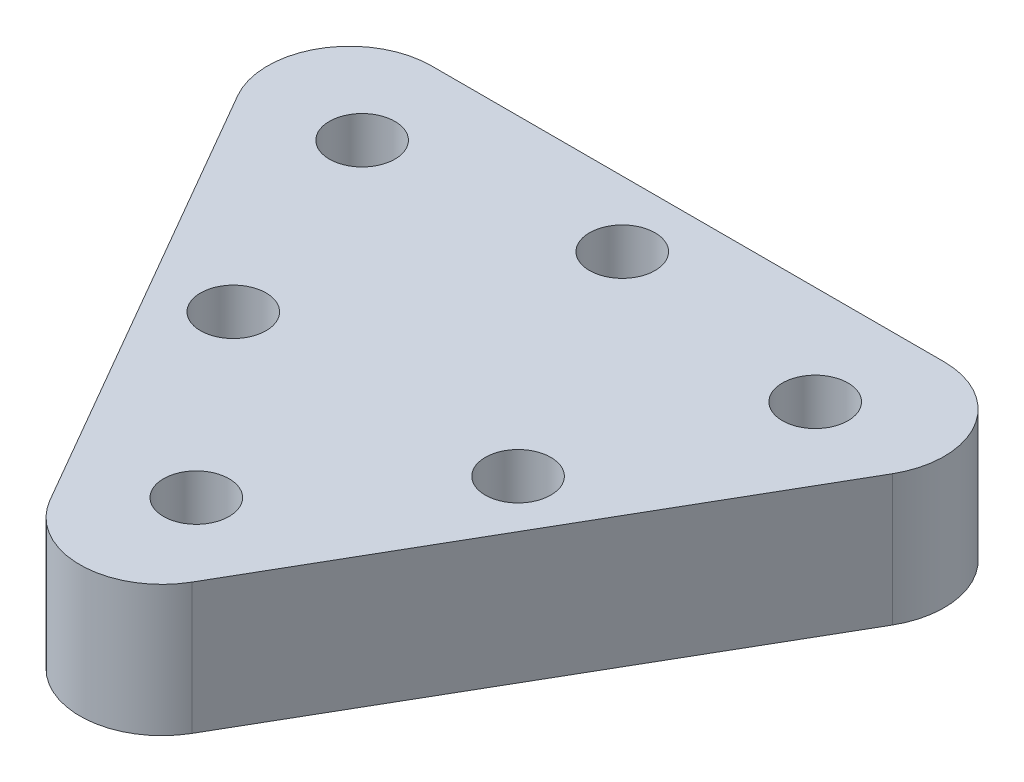
from build123d import *

# Parameters (mm, degrees)
SKETCH1_R                    = 1
EXTRUDE1_DEPTH               = 4
SKETCH1_3_R                  = 2.38125
SKETCH1_3_R_2                = 1
EXTRUDE4_DEPTH               = 2
M2X0_4_TAPPED_HOLE1_D        = 1.6
M2X0_4_TAPPED_HOLE1_DEPTH    = 3
M2X0_4_TAPPED_HOLE1_TIP      = 0.480688495
F_2_0_2_DIAMETER_HOLE1_D     = 2
F_2_0_2_DIAMETER_HOLE1_DEPTH = 10
F_2_0_2_DIAMETER_HOLE1_TIP   = 0.600860619


with BuildPart() as part:
    # Sketch1 → Extrude1 (new body)
    with BuildSketch(Plane(origin=(0, 0, 0), x_dir=(1, 0, 0), z_dir=(0, 1, 0))):
        with BuildLine():
            ThreePointArc((-3.020977638, 7.066192399), (-5.186041147, 5.816192399), (-5.186041147, 3.316192399))
            Line((-5.186041147, 3.316192399), (2.637731834, -10.234979911))
            ThreePointArc((2.637731834, -10.234979911), (4.802795343, -11.484979911), (6.967858853, -10.234979911))
            Line((6.967858853, -10.234979911), (14.791631834, 3.316192399))
            ThreePointArc((14.791631834, 3.316192399), (14.791631834, 5.816192399), (12.626568324, 7.066192399))
            Line((12.626568324, 7.066192399), (-3.020977638, 7.066192399))
        make_face()
        with Locations((4.802795343, -7.933807601)):
            Circle(SKETCH1_R, mode=Mode.SUBTRACT)
        with Locations((-2.110635714, 4.040606244)):
            Circle(SKETCH1_R, mode=Mode.SUBTRACT)
        with Locations((11.7162264, 4.040606244)):
            Circle(SKETCH1_R, mode=Mode.SUBTRACT)
    extrude(amount=EXTRUDE1_DEPTH)

    # Sketch1_3 → Extrude4 (cut)
    # profile 1 of 3: a face of its own
    with BuildSketch(Plane(origin=(0, 0, 0), x_dir=(1, 0, 0), z_dir=(0, 1, 0))):
        with Locations((-2.110635714, 4.040606244)):
            Circle(SKETCH1_3_R)
    # profile 2 of 3: a face of its own
    with BuildSketch(Plane(origin=(0, 0, 0), x_dir=(1, 0, 0), z_dir=(0, 1, 0))):
        with Locations((4.802795343, -7.933807601)):
            Circle(SKETCH1_3_R)
        with Locations((4.802795343, -7.933807601)):
            Circle(SKETCH1_3_R_2, mode=Mode.SUBTRACT)
    # profile 3 of 3: a face of its own
    with BuildSketch(Plane(origin=(0, 0, 0), x_dir=(1, 0, 0), z_dir=(0, 1, 0))):
        with Locations((11.7162264, 4.040606244)):
            Circle(SKETCH1_3_R)
        with Locations((11.7162264, 4.040606244)):
            Circle(SKETCH1_3_R_2, mode=Mode.SUBTRACT)
    extrude(amount=EXTRUDE4_DEPTH, mode=Mode.SUBTRACT)

    # M2x0.4 Tapped Hole1
    with Locations(Plane(origin=(4.802795343, 0, -0.049134963), x_dir=(0, 0, -1), z_dir=(0, -1, 0))):
        with Locations((0, 0)):
            Hole(M2X0_4_TAPPED_HOLE1_D / 2, depth=M2X0_4_TAPPED_HOLE1_DEPTH)
            with Locations((0, 0, -(M2X0_4_TAPPED_HOLE1_DEPTH + M2X0_4_TAPPED_HOLE1_TIP / 2))):  # 118° drill point
                Cone(0, M2X0_4_TAPPED_HOLE1_D / 2, M2X0_4_TAPPED_HOLE1_TIP, mode=Mode.SUBTRACT)

    # Ø2.0 (2) Diameter Hole1
    with Locations(Plane(origin=(0.457896151, 0, 2.459393756), x_dir=(0, 0, -1), z_dir=(0, -1, 0))):
        with Locations((0, 0), (0, 8.689798385), (7.525586155, 4.344899192)):
            Hole(F_2_0_2_DIAMETER_HOLE1_D / 2, depth=F_2_0_2_DIAMETER_HOLE1_DEPTH)
            with Locations((0, 0, -(F_2_0_2_DIAMETER_HOLE1_DEPTH + F_2_0_2_DIAMETER_HOLE1_TIP / 2))):  # 118° drill point
                Cone(0, F_2_0_2_DIAMETER_HOLE1_D / 2, F_2_0_2_DIAMETER_HOLE1_TIP, mode=Mode.SUBTRACT)


solid = part.part
